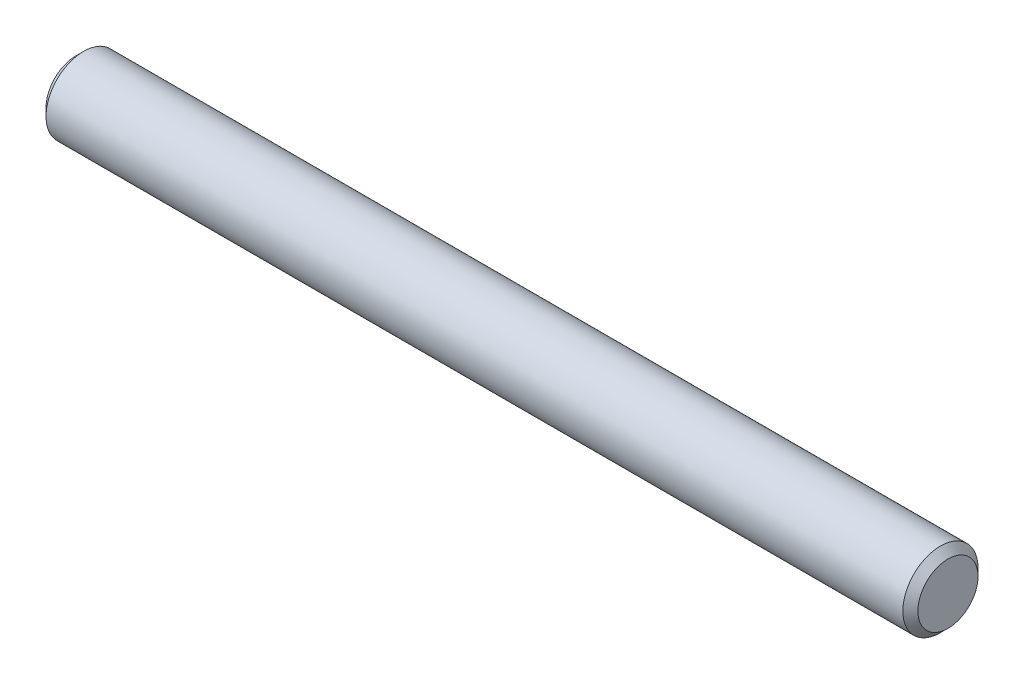
from build123d import *

# Parameters (mm, degrees)
SKETCH1_R      = 5
EXTRUDE1_DEPTH = 116
CHAMFER1_SIZE  = 1


with BuildPart() as part:
    # Sketch1 → Extrude1 (new body)
    with BuildSketch(Plane(origin=(0, 0, 0), x_dir=(0, 0, -1), z_dir=(1, 0, 0))):
        Circle(SKETCH1_R)
    extrude(amount=EXTRUDE1_DEPTH)

    # Chamfer1
    chamfer1_edges = [part.edges().sort_by_distance(p)[0] for p in [
        (0, 0, 5),
        (116, 0, 5),
    ]]
    chamfer(chamfer1_edges, length=CHAMFER1_SIZE)


solid = part.part
